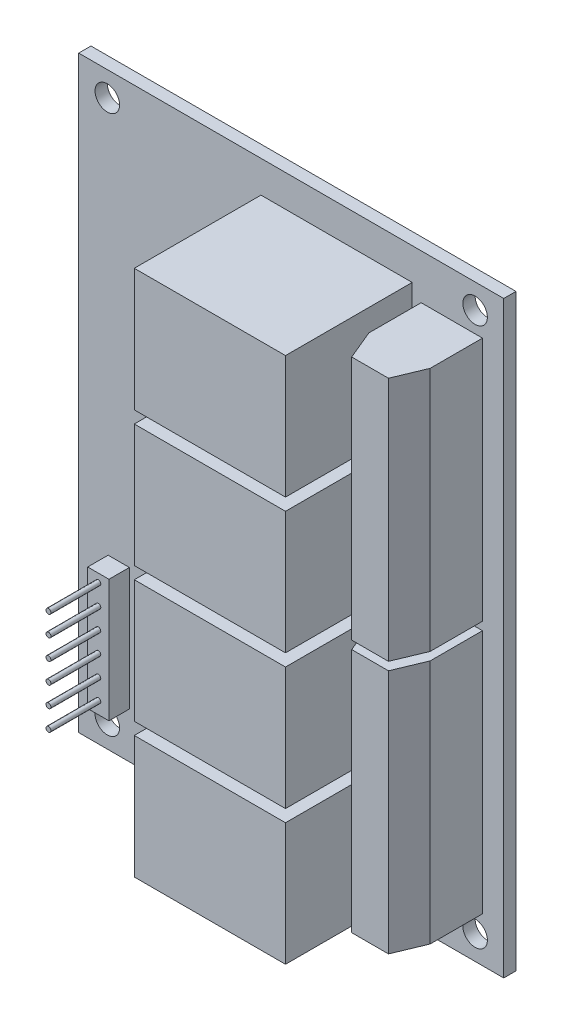
from build123d import *

# Parameters (mm, degrees)
CROQUIS1_W              = 52
CROQUIS1_H              = 72
SALIENTE_EXTRUIR1_DEPTH = 0.75
CROQUIS2_R              = 1.5
CORTAR_EXTRUIR1_DEPTH   = 1.5
CROQUIS3_W              = 18.5
CROQUIS3_H              = 15
SALIENTE_EXTRUIR2_DEPTH = 15.5
CROQUIS4_W              = 7.5
CROQUIS4_H              = 30
SALIENTE_EXTRUIR3_DEPTH = 10
CORTAR_EXTRUIR2_DEPTH   = 80
CROQUIS6_W              = 2.6
CROQUIS6_H              = 15
SALIENTE_EXTRUIR4_DEPTH = 2.5
CROQUIS7_R              = 0.3
SALIENTE_EXTRUIR5_DEPTH = 6.1


with BuildPart() as part:
    # Croquis1 → Saliente-Extruir1 (new body, symmetric)
    with BuildSketch(Plane.XY):
        Rectangle(CROQUIS1_W, CROQUIS1_H)
    extrude(amount=SALIENTE_EXTRUIR1_DEPTH, both=True)

    # Croquis2 → Cortar-Extruir1 (cut)
    with BuildSketch(Plane.XY.offset(0.75)):
        with Locations((-22.5, 33)):
            Circle(CROQUIS2_R)
        with Locations((22.5, 33)):
            Circle(CROQUIS2_R)
        with Locations((-22.5, -33)):
            Circle(CROQUIS2_R)
        with Locations((22.5, -33)):
            Circle(CROQUIS2_R)
    extrude(amount=-CORTAR_EXTRUIR1_DEPTH, mode=Mode.SUBTRACT)

    # Croquis3 → Saliente-Extruir2 (add)
    with BuildSketch(Plane.XY.offset(0.75)):
        with Locations((5.55, -24.9)):
            Rectangle(CROQUIS3_W, CROQUIS3_H)
        with Locations((5.55, -8.4)):
            Rectangle(CROQUIS3_W, CROQUIS3_H)
        with Locations((5.55, 8.1)):
            Rectangle(CROQUIS3_W, CROQUIS3_H)
        with Locations((5.55, 24.6)):
            Rectangle(CROQUIS3_W, CROQUIS3_H)
    extrude(amount=SALIENTE_EXTRUIR2_DEPTH)

    # Croquis4 → Saliente-Extruir3 (add)
    with BuildSketch(Plane.XY.offset(0.75)):
        with Locations((19.65, -15.5)):
            Rectangle(CROQUIS4_W, CROQUIS4_H)
        with Locations((19.65, 15.5)):
            Rectangle(CROQUIS4_W, CROQUIS4_H)
    extrude(amount=SALIENTE_EXTRUIR3_DEPTH)

    # Croquis5 → Cortar-Extruir2 (cut)
    with BuildSketch(Plane.XZ.offset(30.5)):
        Polygon((15.9, 10.75), (15.9, 7.15), (17.4, 10.75), align=None)
        Polygon((23.4, 10.75), (21.9, 10.75), (23.4, 7.15), align=None)
    extrude(amount=-CORTAR_EXTRUIR2_DEPTH, mode=Mode.SUBTRACT)

    # Croquis6 → Saliente-Extruir4 (add)
    with BuildSketch(Plane.XY.offset(0.75)):
        with Locations((-21.1, -22.9)):
            Rectangle(CROQUIS6_W, CROQUIS6_H)
    extrude(amount=SALIENTE_EXTRUIR4_DEPTH)

    # Croquis7 → Saliente-Extruir5 (add)
    with BuildSketch(Plane.XY.offset(3.25)):
        with Locations((-21.1, -28.9)):
            Circle(CROQUIS7_R)
        with Locations((-21.1, -26.4)):
            Circle(CROQUIS7_R)
        with Locations((-21.1, -23.9)):
            Circle(CROQUIS7_R)
        with Locations((-21.1, -21.4)):
            Circle(CROQUIS7_R)
        with Locations((-21.1, -18.9)):
            Circle(CROQUIS7_R)
        with Locations((-21.1, -16.4)):
            Circle(CROQUIS7_R)
    extrude(amount=SALIENTE_EXTRUIR5_DEPTH)


solid = part.part
